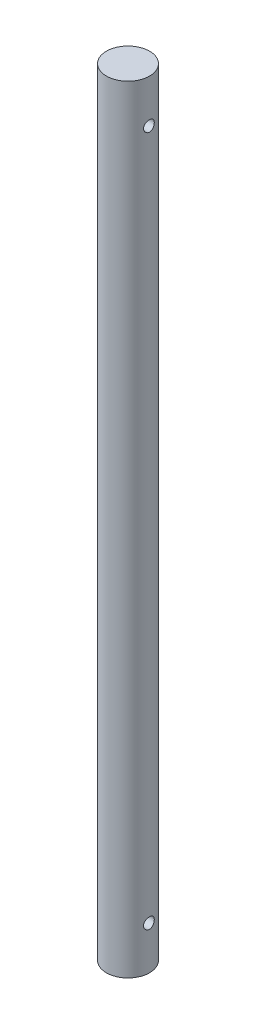
from build123d import *

# Parameters (mm, degrees)
SKETCH1_R               = 25.4
BOSS_EXTRUDE1_DEPTH     = 914.4
SKETCH2_R               = 6.35
CUT_EXTRUDE3_DEPTH      = 26.4
CUT_EXTRUDE3_DEPTH_BACK = 26.4


with BuildPart() as part:
    # Sketch1 → Boss-Extrude1 (new body)
    with BuildSketch(Plane(origin=(0, 0, 0), x_dir=(1, 0, 0), z_dir=(0, 1, 0))):
        Circle(SKETCH1_R)
    extrude(amount=BOSS_EXTRUDE1_DEPTH)

    # Sketch2 → Cut-Extrude3 (cut, two sides)
    with BuildSketch(Plane(origin=(0, 0, 0), x_dir=(0, 0, -1), z_dir=(1, 0, 0))) as cut_extrude3_sk:
        with Locations((0, 863.6)):
            Circle(SKETCH2_R)
        with Locations((0, 50.8)):
            Circle(SKETCH2_R)
    extrude(amount=CUT_EXTRUDE3_DEPTH, mode=Mode.SUBTRACT)
    extrude(cut_extrude3_sk.sketch, amount=-CUT_EXTRUDE3_DEPTH_BACK, mode=Mode.SUBTRACT)


solid = part.part
